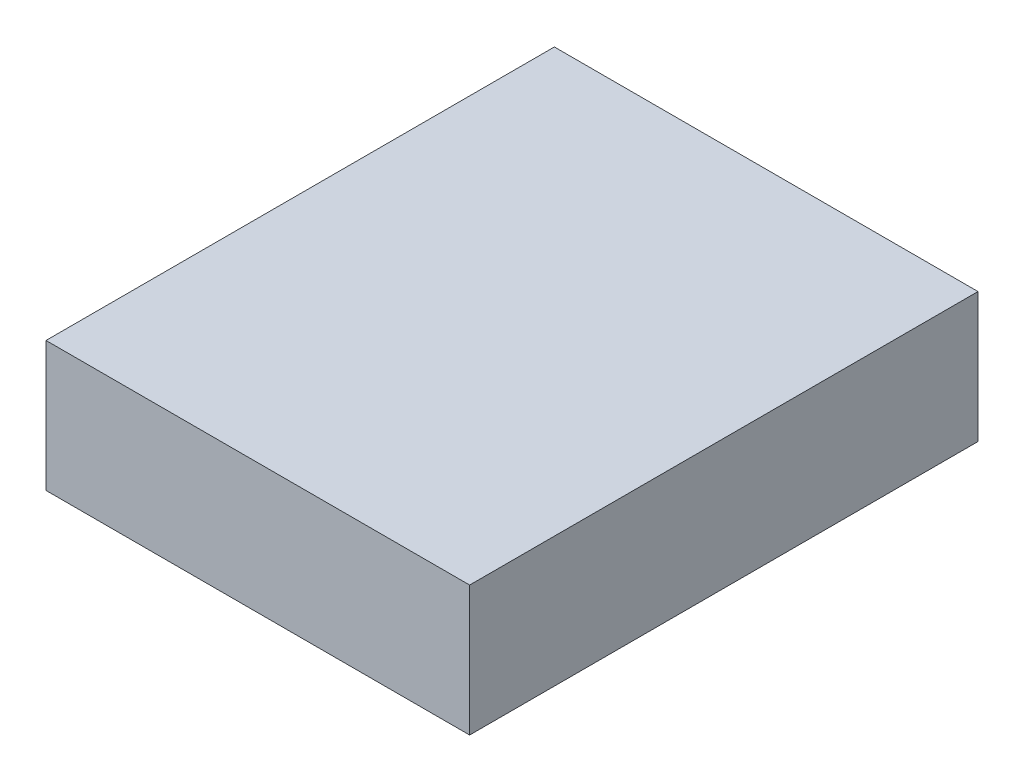
from build123d import *

# Parameters (mm, degrees)
SKETCH1_W           = 1500
SKETCH1_H           = 1800
BOSS_EXTRUDE1_DEPTH = 460


with BuildPart() as part:
    # Sketch1 → Boss-Extrude1 (new body)
    with BuildSketch(Plane(origin=(0, 0, 0), x_dir=(1, 0, 0), z_dir=(0, 1, 0))):
        with Locations((712.437345824, -873.731522248)):
            Rectangle(SKETCH1_W, SKETCH1_H)
    extrude(amount=BOSS_EXTRUDE1_DEPTH)


solid = part.part
